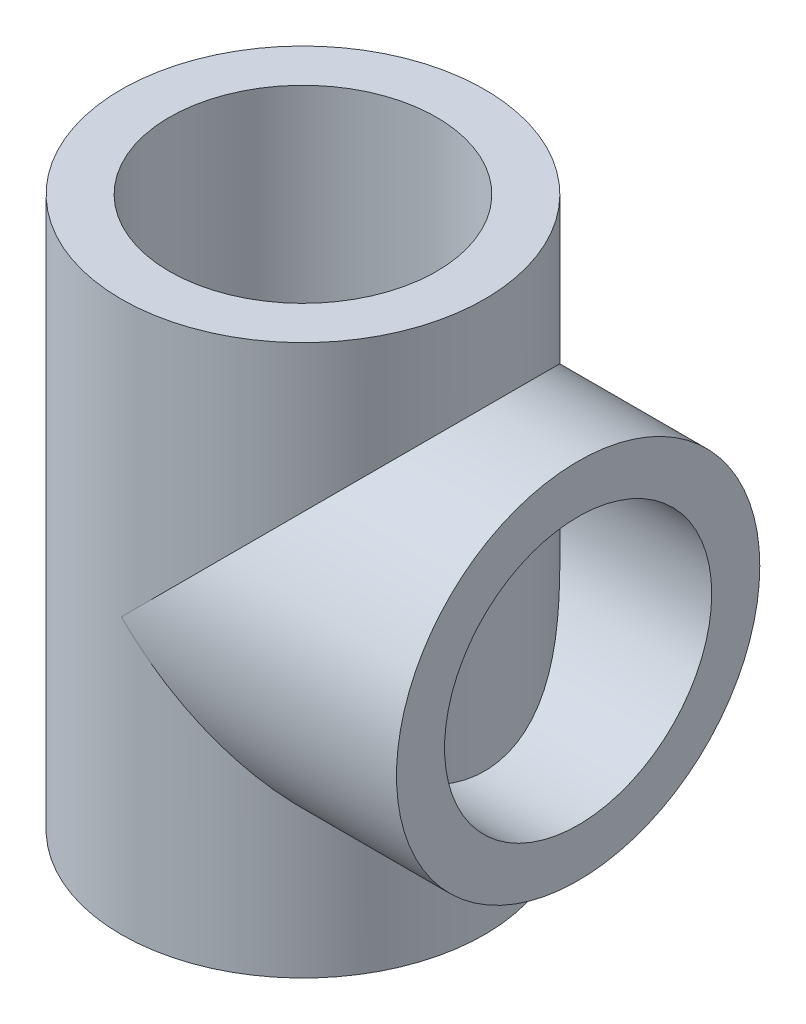
from build123d import *

# Parameters (mm, degrees)
SKETCH1_R           = 34
SKETCH1_R_2         = 25
BOSS_EXTRUDE1_DEPTH = 51.5
BOSS_EXTRUDE2_REACH = 87.5
SKETCH2_R           = 34
SKETCH2_R_2         = 25


with BuildPart() as part:
    # Sketch1 → Boss-Extrude1 (new body, symmetric)
    with BuildSketch(Plane(origin=(0, 0, 0), x_dir=(1, 0, 0), z_dir=(0, 1, 0))):
        Circle(SKETCH1_R)
        Circle(SKETCH1_R_2, mode=Mode.SUBTRACT)
    extrude(amount=BOSS_EXTRUDE1_DEPTH, both=True)

    # Sketch2 → Boss-Extrude2 (add, up to next)
    with BuildSketch(Plane(origin=(51.5, 0, 0), x_dir=(0, 0, -1), z_dir=(1, 0, 0)), mode=Mode.PRIVATE) as boss_extrude2_sk1:
        Circle(SKETCH2_R)
        Circle(SKETCH2_R_2, mode=Mode.SUBTRACT)
    boss_extrude2_tool1 = extrude(boss_extrude2_sk1.sketch, amount=-BOSS_EXTRUDE2_REACH, mode=Mode.PRIVATE) - part.part
    add(boss_extrude2_tool1.solids().sort_by_distance((51.5, 0, 33.038335))[0])


solid = part.part
